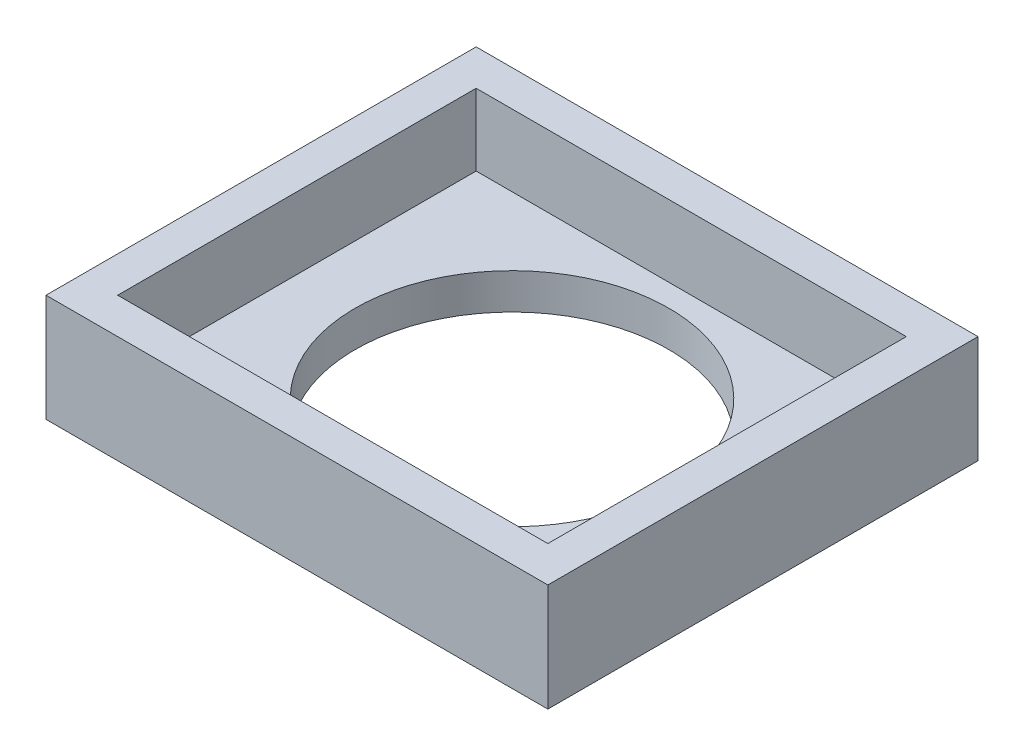
from build123d import *

# Parameters (mm, degrees)
SKETCH1_W           = 28
SKETCH1_H           = 24
SKETCH1_R           = 8.75
BOSS_EXTRUDE1_DEPTH = 2
SKETCH2_W           = 28
SKETCH2_H           = 24
SKETCH2_W_2         = 24
SKETCH2_H_2         = 20
BOSS_EXTRUDE2_DEPTH = 4


with BuildPart() as part:
    # Sketch1 → Boss-Extrude1 (new body)
    with BuildSketch(Plane(origin=(0, 0, 0), x_dir=(1, 0, 0), z_dir=(0, 1, 0))):
        Rectangle(SKETCH1_W, SKETCH1_H)
        Circle(SKETCH1_R, mode=Mode.SUBTRACT)
    extrude(amount=BOSS_EXTRUDE1_DEPTH)

    # Sketch2 → Boss-Extrude2 (add)
    with BuildSketch(Plane(origin=(0, 2, 0), x_dir=(1, 0, 0), z_dir=(0, 1, 0))):
        Rectangle(SKETCH2_W, SKETCH2_H)
        Rectangle(SKETCH2_W_2, SKETCH2_H_2, mode=Mode.SUBTRACT)
    extrude(amount=BOSS_EXTRUDE2_DEPTH)


solid = part.part
